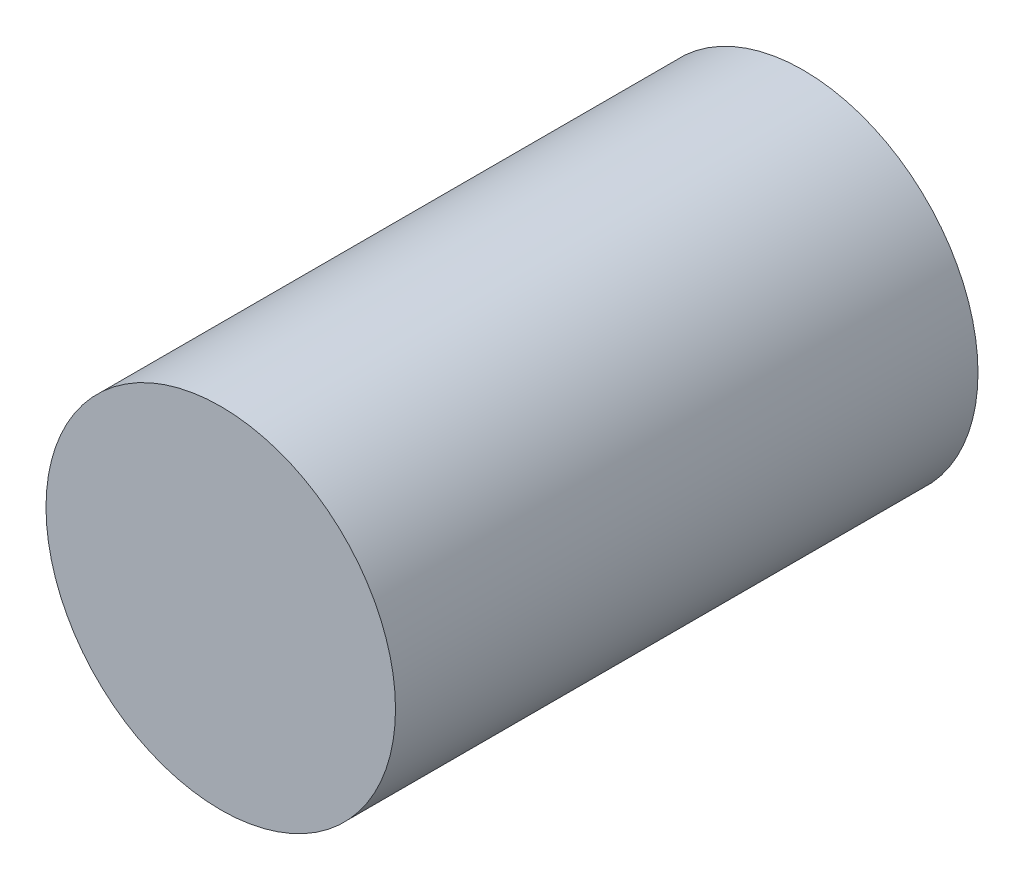
from build123d import *

# Parameters (mm, degrees)
ESQUISSE1_R        = 15
BOSS_EXTRU_1_DEPTH = 50


with BuildPart() as part:
    # Esquisse1 → Boss.-Extru.1 (new body)
    with BuildSketch(Plane.XY):
        Circle(ESQUISSE1_R)
    extrude(amount=BOSS_EXTRU_1_DEPTH)


solid = part.part
